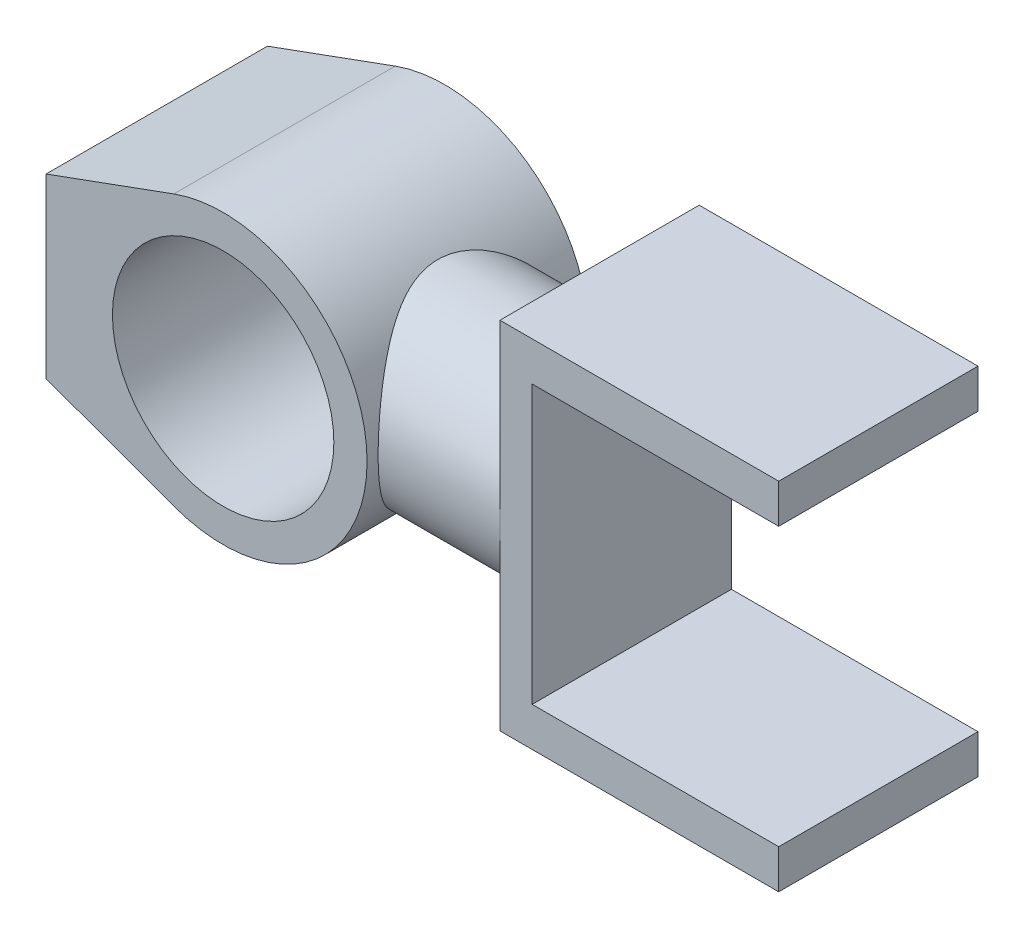
from build123d import *

# Parameters (mm, degrees)
SKETCH1_R                = 50
BOSS_EXTRUDE1_DEPTH      = 50
BOSS_EXTRUDE2_REACH      = 202
SKETCH2_R                = 45
BOSS_EXTRUDE3_DEPTH      = 45
BOSS_EXTRUDE3_DEPTH_BACK = 45


with BuildPart() as part:
    # Sketch1 → Boss-Extrude1 (new body, symmetric)
    with BuildSketch(Plane.XY):
        with BuildLine():
            Line((-80, 40), (-80, -40))
            Line((-80, -40), (-22.281665693, -61.061668614))
            ThreePointArc((-22.281665693, -61.061668614), (65, 0), (-22.281665693, 61.061668614))
            Line((-22.281665693, 61.061668614), (-80, 40))
        make_face()
        Circle(SKETCH1_R, mode=Mode.SUBTRACT)
    extrude(amount=BOSS_EXTRUDE1_DEPTH, both=True)

    # Sketch2 → Boss-Extrude2 (add, up to next)
    with BuildSketch(Plane(origin=(120, 0, 0), x_dir=(0, 0, -1), z_dir=(1, 0, 0)), mode=Mode.PRIVATE) as boss_extrude2_sk1:
        Circle(SKETCH2_R)
    boss_extrude2_tool1 = extrude(boss_extrude2_sk1.sketch, amount=-BOSS_EXTRUDE2_REACH, mode=Mode.PRIVATE) - part.part
    add(boss_extrude2_tool1.solids().sort_by_distance((120, 0, 0))[0])

    # Sketch3 → Boss-Extrude3 (add, two sides)
    with BuildSketch(Plane.XY) as boss_extrude3_sk:
        Polygon((120, 45), (120, 80.306694099), (245.903834127, 80.306694099), (245.903834127, 62.653347049), (134.550333897, 62.653347049), (134.550333897, -62.653347049), (245.903834127, -62.653347049), (245.903834127, -80.306694099), (120, -80.306694099), (120, -45), align=None)
    extrude(amount=BOSS_EXTRUDE3_DEPTH)
    extrude(boss_extrude3_sk.sketch, amount=-BOSS_EXTRUDE3_DEPTH_BACK)


solid = part.part
